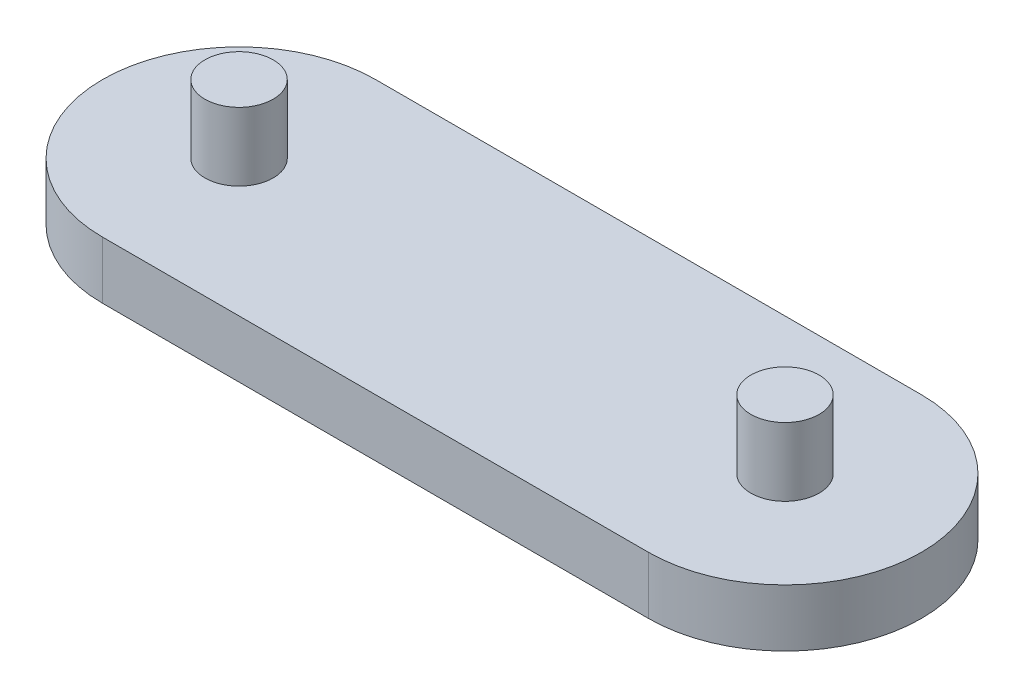
from build123d import *

# Parameters (mm, degrees)
BOSS_EXTRUDE1_DEPTH = 42
SKETCH3_R           = 25
BOSS_EXTRUDE2_DEPTH = 50
SKETCH4_R           = 25
BOSS_EXTRUDE3_DEPTH = 50


with BuildPart() as part:
    # Sketch2 → Boss-Extrude1 (new body)
    with BuildSketch(Plane(origin=(0, 0, 0), x_dir=(1, 0, 0), z_dir=(0, 1, 0))):
        with BuildLine():
            Line((0, -100), (-400, -100))
            ThreePointArc((-400, -100), (-500, 0), (-400, 100))
            Line((-400, 100), (0, 100))
            ThreePointArc((0, 100), (100, 0), (0, -100))
        make_face()
    extrude(amount=BOSS_EXTRUDE1_DEPTH)

    # Sketch3 → Boss-Extrude2 (add)
    with BuildSketch(Plane(origin=(0, 42, 0), x_dir=(1, 0, 0), z_dir=(0, 1, 0))):
        Circle(SKETCH3_R)
    extrude(amount=BOSS_EXTRUDE2_DEPTH)

    # Sketch4 → Boss-Extrude3 (add)
    with BuildSketch(Plane(origin=(0, 42, 0), x_dir=(1, 0, 0), z_dir=(0, 1, 0))):
        with Locations((-400, 0)):
            Circle(SKETCH4_R)
    extrude(amount=BOSS_EXTRUDE3_DEPTH)


solid = part.part
